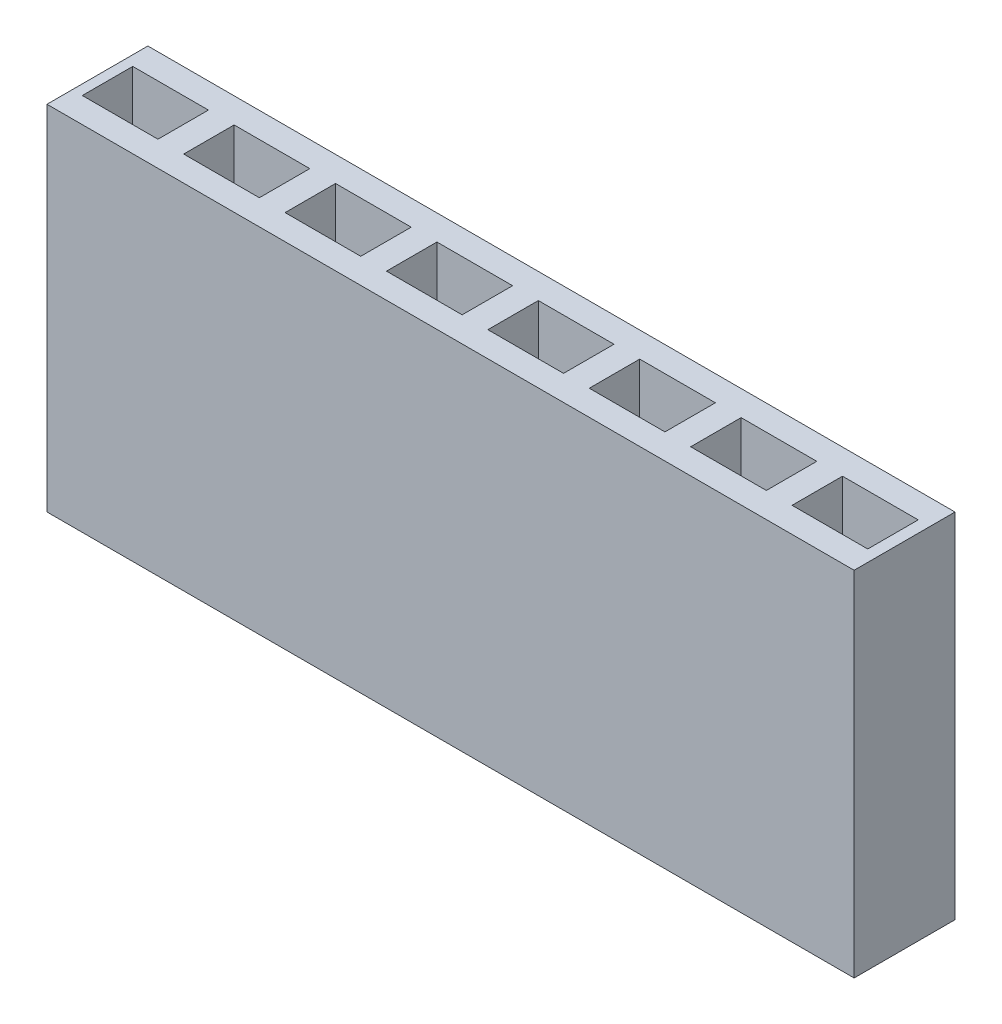
from build123d import *

# Parameters (mm, degrees)
SKETCH1_W           = 16
SKETCH1_H           = 7
BOSS_EXTRUDE1_DEPTH = 2
SKETCH2_W           = 1.5
SKETCH2_H           = 1
CUT_EXTRUDE1_DEPTH  = 4
LPATTERN1_COUNT     = 8
LPATTERN1_PITCH     = 2.01


with BuildPart() as part:
    # Sketch1 → Boss-Extrude1 (new body)
    with BuildSketch(Plane.XY):
        with Locations((8, 3.5)):
            Rectangle(SKETCH1_W, SKETCH1_H)
    extrude(amount=BOSS_EXTRUDE1_DEPTH)

    # Sketch2 → Cut-Extrude1 (cut)
    with BuildSketch(Plane(origin=(0, 7, 0), x_dir=(1, 0, 0), z_dir=(0, 1, 0))):
        with Locations((0.95, -1)):
            Rectangle(SKETCH2_W, SKETCH2_H)
    cut_extrude1 = extrude(amount=-CUT_EXTRUDE1_DEPTH, mode=Mode.SUBTRACT)

    # LPattern1: Cut-Extrude1 ×8
    with Locations(*[(i * LPATTERN1_PITCH, 0, 0) for i in range(1, LPATTERN1_COUNT)]):
        add(cut_extrude1, mode=Mode.SUBTRACT)


solid = part.part
